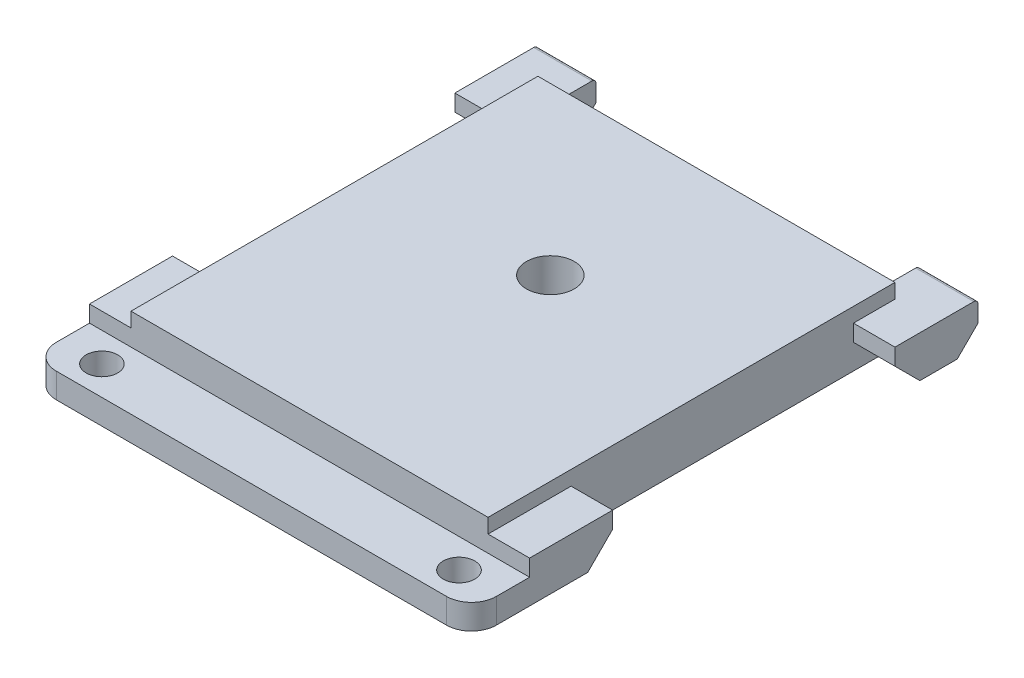
from build123d import *

# Parameters (mm, degrees)
SKETCH1_W           = 43
SKETCH1_H           = 49
SKETCH1_R           = 2.875
BOSS_EXTRUDE1_DEPTH = 6.75
SKETCH2_W           = 49
SKETCH2_H           = 5
BOSS_EXTRUDE2_DEPTH = 5
SKETCH3_W           = 49
SKETCH3_H           = 5
BOSS_EXTRUDE3_DEPTH = 5
SKETCH4_W           = 7
SKETCH4_H           = 5
BOSS_EXTRUDE4_DEPTH = 5
CHAMFER1_SIZE       = 2.5
FILLET1_R           = 0.5
SKETCH6_W           = 53
SKETCH6_H           = 3
BOSS_EXTRUDE6_DEPTH = 7
SKETCH7_R           = 1.9
CUT_EXTRUDE1_DEPTH  = 3
SKETCH9_W           = 34
SKETCH9_H           = 5
CUT_EXTRUDE2_DEPTH  = 5
SKETCH10_W          = 34
SKETCH10_H          = 5
CUT_EXTRUDE3_DEPTH  = 5
CHAMFER2_SIZE       = 3
FILLET2_R           = 3


with BuildPart() as part:
    # Sketch1 → Boss-Extrude1 (new body)
    with BuildSketch(Plane(origin=(0, 0, 0), x_dir=(1, 0, 0), z_dir=(0, 1, 0))):
        with Locations((21.5, -24.5)):
            Rectangle(SKETCH1_W, SKETCH1_H)
        with Locations((21.5, -20)):
            Circle(SKETCH1_R, mode=Mode.SUBTRACT)
    extrude(amount=BOSS_EXTRUDE1_DEPTH)

    # Sketch2 → Boss-Extrude2 (add)
    with BuildSketch(Plane.ZY):
        with Locations((24.5, 2.5)):
            Rectangle(SKETCH2_W, SKETCH2_H)
    extrude(amount=BOSS_EXTRUDE2_DEPTH)

    # Sketch3 → Boss-Extrude3 (add)
    with BuildSketch(Plane(origin=(43, 0, 0), x_dir=(0, 0, -1), z_dir=(1, 0, 0))):
        with Locations((-24.5, 2.5)):
            Rectangle(SKETCH3_W, SKETCH3_H)
    extrude(amount=BOSS_EXTRUDE3_DEPTH)

    # Sketch4 → Boss-Extrude4 (add)
    with BuildSketch(Plane(origin=(0, 0, 0), x_dir=(-1, 0, 0), z_dir=(0, 0, -1))):
        with Locations((-44.5, 2.5)):
            Rectangle(SKETCH4_W, SKETCH4_H)
        with Locations((1.5, 2.5)):
            Rectangle(SKETCH4_W, SKETCH4_H)
    extrude(amount=BOSS_EXTRUDE4_DEPTH)

    # Chamfer1
    chamfer1_edges = [part.edges().sort_by_distance(p)[0] for p in [
        (44.5, 0, -5),
        (-1.5, 0, -5),
    ]]
    chamfer(chamfer1_edges, length=CHAMFER1_SIZE)

    # Fillet1
    fillet1_edges = [part.edges().sort_by_distance(p)[0] for p in [
        (44.5, 5, -5),
        (-1.5, 5, -5),
    ]]
    fillet(fillet1_edges, radius=FILLET1_R)

    # Sketch6 → Boss-Extrude6 (add)
    with BuildSketch(Plane.XY.offset(49)):
        with Locations((21.5, 1.5)):
            Rectangle(SKETCH6_W, SKETCH6_H)
    extrude(amount=BOSS_EXTRUDE6_DEPTH)

    # Sketch7 → Cut-Extrude1 (cut)
    with BuildSketch(Plane(origin=(0, 3, 0), x_dir=(1, 0, 0), z_dir=(0, 1, 0))):
        with Locations((0, -52.5)):
            Circle(SKETCH7_R)
        with Locations((43, -52.5)):
            Circle(SKETCH7_R)
    extrude(amount=-CUT_EXTRUDE1_DEPTH, mode=Mode.SUBTRACT)

    # Sketch9 → Cut-Extrude2 (cut)
    with BuildSketch(Plane.ZY.offset(5)):
        with Locations((22, 2.5)):
            Rectangle(SKETCH9_W, SKETCH9_H)
    extrude(amount=-CUT_EXTRUDE2_DEPTH, mode=Mode.SUBTRACT)

    # Sketch10 → Cut-Extrude3 (cut)
    with BuildSketch(Plane(origin=(48, 0, 0), x_dir=(0, 0, -1), z_dir=(1, 0, 0))):
        with Locations((-22, 2.5)):
            Rectangle(SKETCH10_W, SKETCH10_H)
    extrude(amount=-CUT_EXTRUDE3_DEPTH, mode=Mode.SUBTRACT)

    # Chamfer2
    chamfer2_edges = [part.edges().sort_by_distance(p)[0] for p in [
        (-2.5, 0, 5),
        (-2.5, 0, 39),
        (45.5, 0, 39),
        (45.5, 0, 5),
    ]]
    chamfer(chamfer2_edges, length=CHAMFER2_SIZE)

    # Fillet2
    fillet2_edges = [part.edges().sort_by_distance(p)[0] for p in [
        (-5, 1.5, 56),
        (48, 1.5, 56),
    ]]
    fillet(fillet2_edges, radius=FILLET2_R)


solid = part.part
